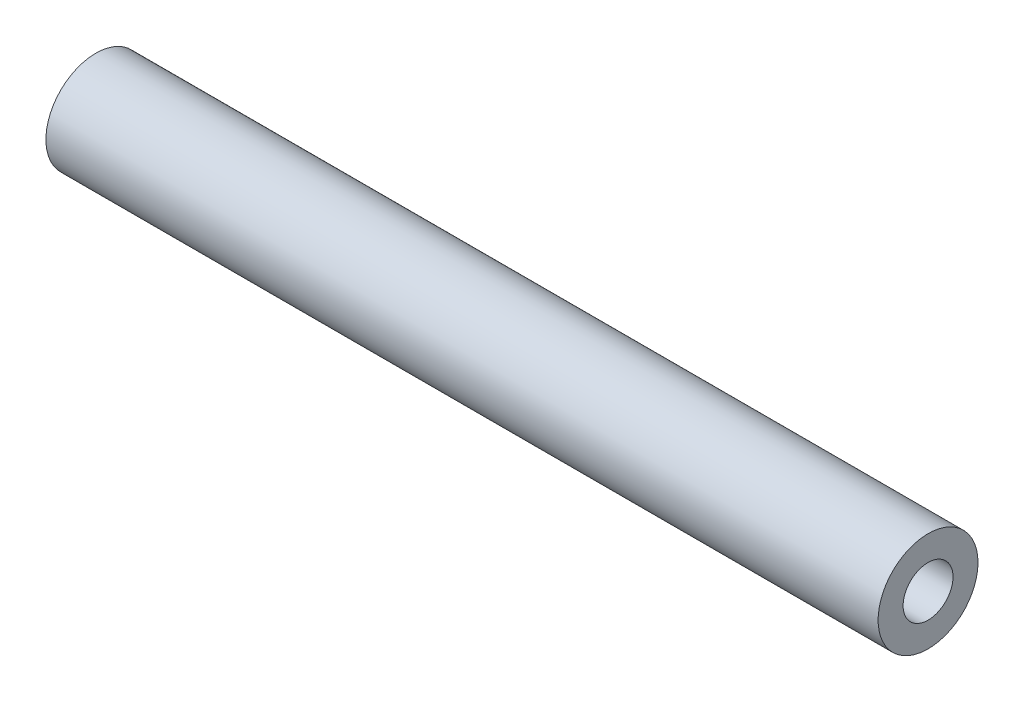
from build123d import *

# Parameters (mm, degrees)
SKETCH1_R           = 6
BOSS_EXTRUDE1_DEPTH = 100
SKETCH2_R           = 3
CUT_EXTRUDE1_DEPTH  = 30
SKETCH3_R           = 3
CUT_EXTRUDE2_DEPTH  = 60


with BuildPart() as part:
    # Sketch1 → Boss-Extrude1 (new body)
    with BuildSketch(Plane(origin=(0, 0, 0), x_dir=(0, 0, -1), z_dir=(1, 0, 0))):
        Circle(SKETCH1_R)
    extrude(amount=BOSS_EXTRUDE1_DEPTH)

    # Sketch2 → Cut-Extrude1 (cut)
    with BuildSketch(Plane(origin=(100, 0, 0), x_dir=(0, 0, -1), z_dir=(1, 0, 0))):
        Circle(SKETCH2_R)
    extrude(amount=-CUT_EXTRUDE1_DEPTH, mode=Mode.SUBTRACT)

    # Sketch3 → Cut-Extrude2 (cut)
    with BuildSketch(Plane.ZY):
        Circle(SKETCH3_R)
    extrude(amount=-CUT_EXTRUDE2_DEPTH, mode=Mode.SUBTRACT)


solid = part.part
